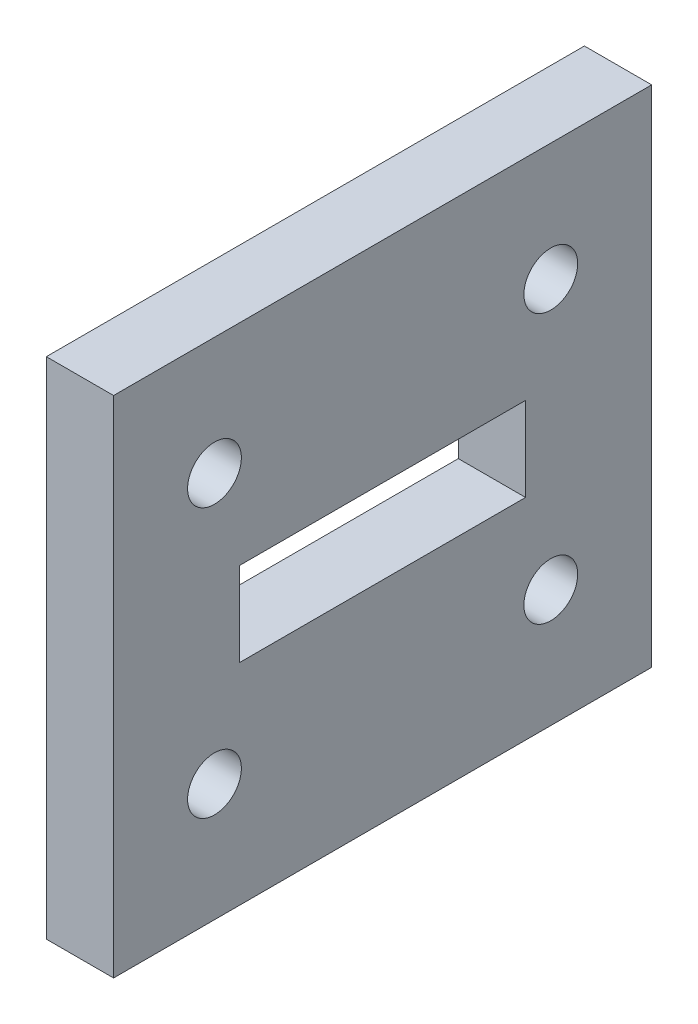
from build123d import *

# Parameters (mm, degrees)
SKETCH_1_W         = 32
SKETCH_1_H         = 30
SKETCH_1_R         = 1.6
EXTRUDE_1_DEPTH    = 4
SKETCH2_W          = 17
SKETCH2_H          = 5
CUT_EXTRUDE2_DEPTH = 5


with BuildPart() as part:
    # Эскиз1 → Бобышка-Вытянуть1 (new body)
    with BuildSketch(Plane(origin=(15.473923778, 0, 0), x_dir=(0, 0, -1), z_dir=(1, 0, 0))):
        with Locations((2.763696673, 23.493617857)):
            Rectangle(SKETCH_1_W, SKETCH_1_H)
        with Locations((-7.236303327, 31.493617857)):
            Circle(SKETCH_1_R, mode=Mode.SUBTRACT)
        with Locations((12.763696673, 31.493617857)):
            Circle(SKETCH_1_R, mode=Mode.SUBTRACT)
        with Locations((-7.236303327, 15.493617857)):
            Circle(SKETCH_1_R, mode=Mode.SUBTRACT)
        with Locations((12.763696673, 15.493617857)):
            Circle(SKETCH_1_R, mode=Mode.SUBTRACT)
    extrude(amount=EXTRUDE_1_DEPTH)

    # Sketch2 → Cut-Extrude2 (cut, through all)
    with BuildSketch(Plane.ZY.offset(-15.473923778)):
        with Locations((-2.763696673, 23.493617857)):
            Rectangle(SKETCH2_W, SKETCH2_H)
    extrude(amount=-CUT_EXTRUDE2_DEPTH, mode=Mode.SUBTRACT)


solid = part.part
